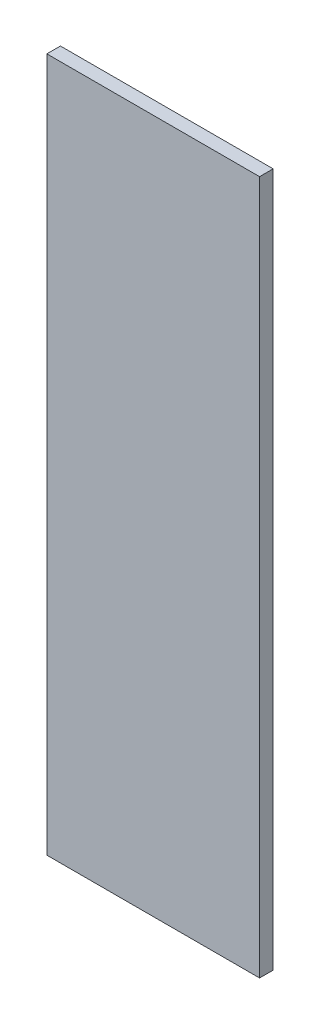
from build123d import *

# Parameters (mm, degrees)
SKETCH_1_W      = 282
SKETCH_1_H      = 920
EXTRUDE_1_DEPTH = 18


with BuildPart() as part:
    # Эскиз1 → Бобышка-Вытянуть1 (new body)
    with BuildSketch(Plane.XY):
        Rectangle(SKETCH_1_W, SKETCH_1_H)
    extrude(amount=EXTRUDE_1_DEPTH)


solid = part.part
